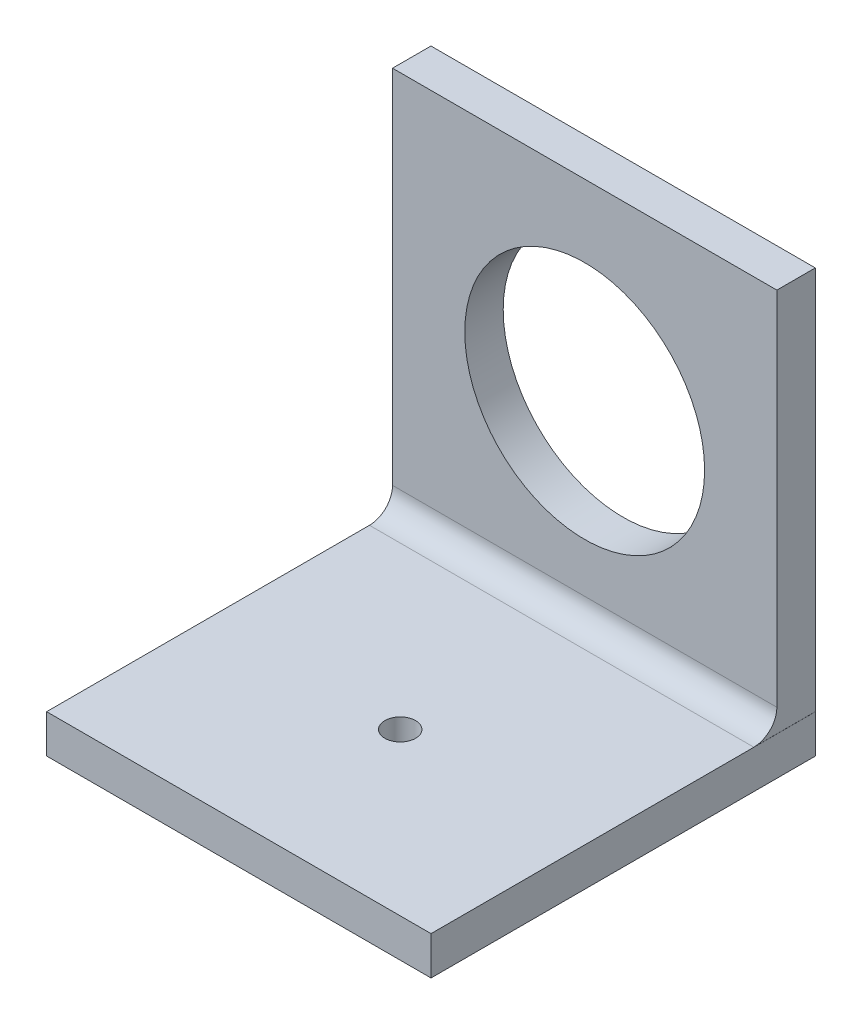
from build123d import *

# Parameters (mm, degrees)
ESBO_O1_W                  = 50
ESBO_O1_H                  = 50
RESSALTO_EXTRUS_O1_DEPTH   = 5
ESBO_O2_R                  = 15.6
CORTE_EXTRUS_O1_DEPTH      = 8
CORTE_EXTRUS_O1_DEPTH_BACK = 14
ESBO_O3_W                  = 50.011024838
ESBO_O3_H                  = 5
RESSALTO_EXTRUS_O2_DEPTH   = 50
FILETE1_R                  = 3
ESBO_O5_R                  = 2
CORTE_EXTRUS_O4_DEPTH      = 14


with BuildPart() as part:
    # Esboço1 → Ressalto-extrusão1 (new body)
    with BuildSketch(Plane.XY):
        with Locations((25, 25)):
            Rectangle(ESBO_O1_W, ESBO_O1_H)
    extrude(amount=RESSALTO_EXTRUS_O1_DEPTH)

    # Esboço2 → Corte-extrusão1 (cut, two sides)
    with BuildSketch(Plane.XY) as corte_extrus_o1_sk:
        with Locations((25, 25)):
            Circle(ESBO_O2_R)
    extrude(amount=CORTE_EXTRUS_O1_DEPTH, mode=Mode.SUBTRACT)
    extrude(corte_extrus_o1_sk.sketch, amount=-CORTE_EXTRUS_O1_DEPTH_BACK, mode=Mode.SUBTRACT)

    # Esboço3 → Ressalto-extrusão2 (add)
    with BuildSketch(Plane.XY):
        with Locations((25.005512419, -2.5)):
            Rectangle(ESBO_O3_W, ESBO_O3_H)
    extrude(amount=RESSALTO_EXTRUS_O2_DEPTH)

    # Filete1
    filete1_edges = [part.edges().sort_by_distance(p)[0] for p in [
        (25, 0, 5),
    ]]
    fillet(filete1_edges, radius=FILETE1_R)

    # Esboço5 → Corte-extrusão4 (cut)
    with BuildSketch(Plane(origin=(0, 0, 0), x_dir=(1, 0, 0), z_dir=(0, 1, 0))):
        with Locations((25.002756209, -29)):
            Circle(ESBO_O5_R)
    extrude(amount=-CORTE_EXTRUS_O4_DEPTH, mode=Mode.SUBTRACT)


solid = part.part
